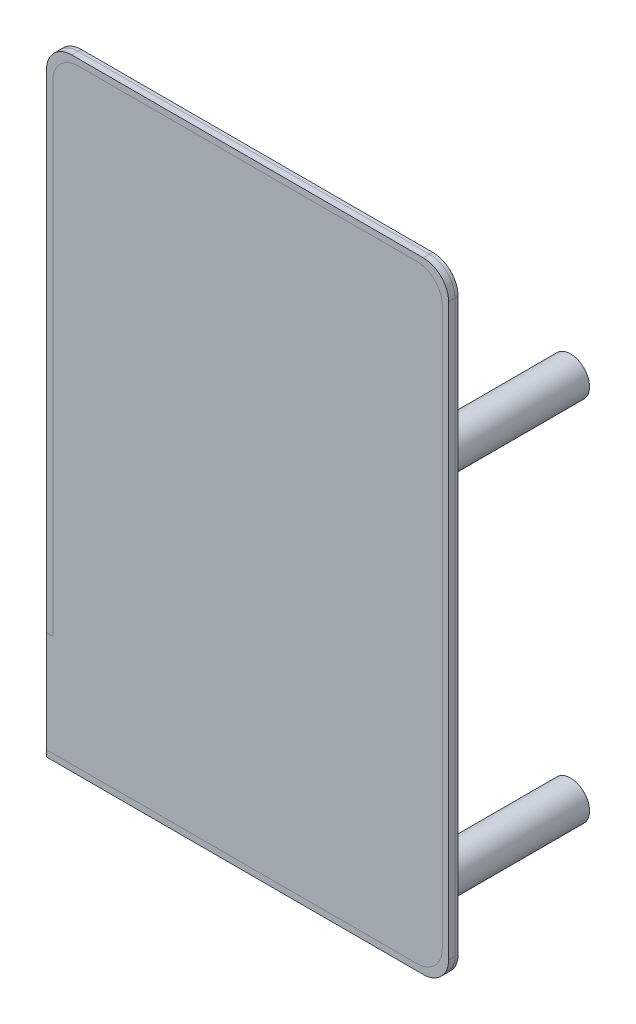
from build123d import *

# Parameters (mm, degrees)
SKETCH1_W           = 98
SKETCH1_H           = 63.5
BOSS_EXTRUDE1_DEPTH = 1.5
SKETCH1_3_W         = 94.6
SKETCH1_3_H         = 60.1
SKETCH1_3_W_2       = 91.6
SKETCH1_3_H_2       = 57.1
BOSS_EXTRUDE2_DEPTH = 1.5
SKETCH1_5_R         = 3
SKETCH1_5_R_2       = 0.95
BOSS_EXTRUDE3_DEPTH = 25
CUT_EXTRUDE1_DEPTH  = 1
FILLET1_R           = 4
BOSS_EXTRUDE4_DEPTH = 1
FILLET2_R           = 4


with BuildPart() as part:
    # Sketch1 → Boss-Extrude1 (new body)
    with BuildSketch(Plane(origin=(0, 0, 0), x_dir=(0, 1, 0), z_dir=(0, 0, 1))):
        with Locations((13.535644201, -8.565962884)):
            Rectangle(SKETCH1_W, SKETCH1_H)
    extrude(amount=BOSS_EXTRUDE1_DEPTH)

    # Sketch1_3 → Boss-Extrude2 (add)
    with BuildSketch(Plane(origin=(0, 0, 0), x_dir=(0, 1, 0), z_dir=(0, 0, 1))):
        with Locations((13.535644201, -8.565962884)):
            Rectangle(SKETCH1_3_W, SKETCH1_3_H)
        with Locations((13.535644201, -8.565962884)):
            Rectangle(SKETCH1_3_W_2, SKETCH1_3_H_2, mode=Mode.SUBTRACT)
    extrude(amount=-BOSS_EXTRUDE2_DEPTH)

    # Sketch1_5 → Boss-Extrude3 (add)
    with BuildSketch(Plane(origin=(0, 0, 0), x_dir=(0, 1, 0), z_dir=(0, 0, 1))):
        with Locations((31.535644201, -33.065962884)):
            Circle(SKETCH1_5_R)
        with Locations((31.535644201, -33.065962884)):
            Circle(SKETCH1_5_R_2, mode=Mode.SUBTRACT)
        with Locations((31.535644201, 15.934037116)):
            Circle(SKETCH1_5_R)
        with Locations((31.535644201, 15.934037116)):
            Circle(SKETCH1_5_R_2, mode=Mode.SUBTRACT)
        with Locations((-26.464355799, 15.934037116)):
            Circle(SKETCH1_5_R)
        with Locations((-26.464355799, 15.934037116)):
            Circle(SKETCH1_5_R_2, mode=Mode.SUBTRACT)
        with Locations((-26.464355799, -33.065962884)):
            Circle(SKETCH1_5_R)
        with Locations((-26.464355799, -33.065962884)):
            Circle(SKETCH1_5_R_2, mode=Mode.SUBTRACT)
    extrude(amount=-BOSS_EXTRUDE3_DEPTH)

    # Sketch3 → Cut-Extrude1 (cut)
    with BuildSketch(Plane.XY.offset(1.5)):
        Polygon((40.315962884, 62.535644201), (-23.184037116, 62.535644201), (-23.184037116, -18.464355799), (-22.184037116, -18.464355799), (-22.184037116, 61.535644201), (39.315962884, 61.535644201), (39.315962884, -34.464355799), (-22.184037116, -34.464355799), (-23.184037116, -34.464355799), (-23.184037116, -35.464355799), (40.315962884, -35.464355799), align=None)
    extrude(amount=-CUT_EXTRUDE1_DEPTH, mode=Mode.SUBTRACT)

    # Fillet1
    fillet1_edges = [part.edges().sort_by_distance(p)[0] for p in [
        (38.615962884, -33.764355799, -0.75),
        (-21.484037116, 60.835644201, -0.75),
        (38.615962884, 60.835644201, -0.75),
        (-19.984037116, 59.335644201, -0.75),
        (37.115962884, 59.335644201, -0.75),
        (37.115962884, -32.264355799, -0.75),
        (-23.184037116, 62.535644201, 0.25),
        (40.315962884, 62.535644201, 0.25),
        (40.315962884, -35.464355799, 0.25),
        (39.315962884, -34.464355799, 1),
        (39.315962884, 61.535644201, 1),
        (-22.184037116, 61.535644201, 1),
    ]]
    fillet(fillet1_edges, radius=FILLET1_R)


with BuildPart() as body_2:
    # Sketch3_3 → Boss-Extrude4 (new body)
    with BuildSketch(Plane.XY.offset(1.5)):
        Polygon((40.315962884, 62.535644201), (-23.184037116, 62.535644201), (-23.184037116, -18.464355799), (-22.184037116, -18.464355799), (-22.184037116, 61.535644201), (39.315962884, 61.535644201), (39.315962884, -34.464355799), (-22.184037116, -34.464355799), (-23.184037116, -34.464355799), (-23.184037116, -35.464355799), (40.315962884, -35.464355799), align=None)
    extrude(amount=-BOSS_EXTRUDE4_DEPTH)

    # Fillet2
    fillet2_edges = [body_2.edges().sort_by_distance(p)[0] for p in [
        (-22.184037116, 61.535644201, 1),
        (39.315962884, 61.535644201, 1),
        (39.315962884, -34.464355799, 1),
        (40.315962884, -35.464355799, 1),
        (40.315962884, 62.535644201, 1),
        (-23.184037116, 62.535644201, 1),
    ]]
    fillet(fillet2_edges, radius=FILLET2_R)


solid = Compound([part.part, body_2.part])
